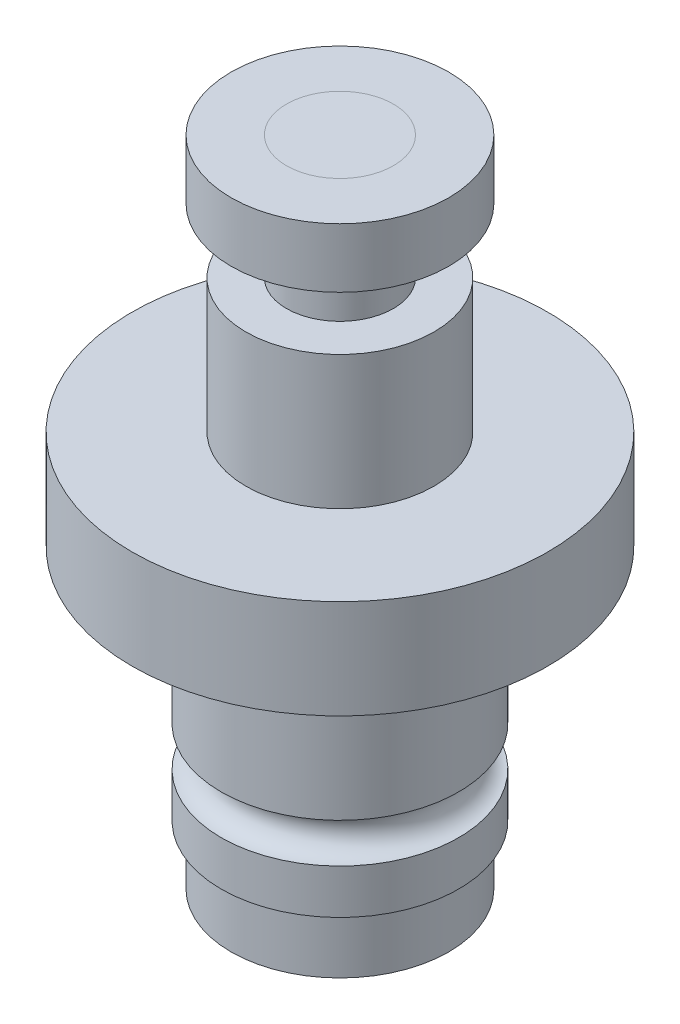
from build123d import *

# Parameters (mm, degrees)
BOSS_EXTRUDE1_DEPTH      = 2.5
BOSS_EXTRUDE1_DEPTH_BACK = 2.5
SKETCH1_R                = 10.5
SKETCH2_R                = 4.75
BOSS_EXTRUDE2_DEPTH      = 6.75
SKETCH3_R                = 2.7
BOSS_EXTRUDE4_DEPTH      = 6.25
SKETCH5_R                = 5.5
SKETCH5_R_2              = 2.7
BOSS_EXTRUDE5_DEPTH      = 3
SKETCH6_R                = 2.5
BOSS_EXTRUDE6_DEPTH      = 15
SKETCH7_R                = 4.875
SKETCH7_R_2              = 2.5
BOSS_EXTRUDE7_DEPTH      = 1
SKETCH8_R                = 6
SKETCH8_R_2              = 2.5
BOSS_EXTRUDE8_DEPTH      = 11
SKETCH9_R                = 1
SKETCH10_R               = 5.5
SKETCH10_R_2             = 2.5
BOSS_EXTRUDE12_DEPTH     = 3


with BuildPart() as part:
    # Sketch1 → Boss-Extrude1 (new, two sides: drawn at the far end of the back side and taken through both)
    with BuildSketch(Plane(origin=(0, 0, 0), x_dir=(1, 0, 0), z_dir=(0, 1, 0)).offset(-BOSS_EXTRUDE1_DEPTH_BACK)):
        Circle(SKETCH1_R)
    extrude(amount=BOSS_EXTRUDE1_DEPTH + BOSS_EXTRUDE1_DEPTH_BACK)

    # Sketch2 → Boss-Extrude2 (add)
    with BuildSketch(Plane(origin=(0, 2.5, 0), x_dir=(1, 0, 0), z_dir=(0, 1, 0))):
        Circle(SKETCH2_R)
    extrude(amount=BOSS_EXTRUDE2_DEPTH)

    # Sketch3 → Boss-Extrude4 (add)
    with BuildSketch(Plane(origin=(0, 9.25, 0), x_dir=(1, 0, 0), z_dir=(0, 1, 0))):
        Circle(SKETCH3_R)
    extrude(amount=BOSS_EXTRUDE4_DEPTH)


with BuildPart() as body_2:
    # Sketch5 → Boss-Extrude5 (new body)
    with BuildSketch(Plane(origin=(0, 15.5, 0), x_dir=(1, 0, 0), z_dir=(0, 1, 0))):
        Circle(SKETCH5_R)
        Circle(SKETCH5_R_2, mode=Mode.SUBTRACT)
    extrude(amount=-BOSS_EXTRUDE5_DEPTH)


with BuildPart() as body_3:
    # Sketch6 → Boss-Extrude6 (new body)
    with BuildSketch(Plane.XZ.offset(2.5)):
        Circle(SKETCH6_R)
    extrude(amount=BOSS_EXTRUDE6_DEPTH)


with BuildPart() as body_4:
    # Sketch7 → Boss-Extrude7 (new body)
    with BuildSketch(Plane.XZ.offset(2.5)):
        Circle(SKETCH7_R)
        Circle(SKETCH7_R_2, mode=Mode.SUBTRACT)
    extrude(amount=BOSS_EXTRUDE7_DEPTH)


with BuildPart() as body_5:
    # Sketch8 → Boss-Extrude8 (new body)
    with BuildSketch(Plane.XZ.offset(3.5)):
        Circle(SKETCH8_R)
        Circle(SKETCH8_R_2, mode=Mode.SUBTRACT)
    extrude(amount=BOSS_EXTRUDE8_DEPTH)

    # Sketch9 → Cut-Revolve1 (revolve, cut)
    with BuildSketch(Plane.XY):
        with Locations((6, -11.25)):
            Circle(SKETCH9_R)
    revolve(axis=Axis((0, -29.718418544, 0), (0, 1, 0)), mode=Mode.SUBTRACT)


with BuildPart() as body_6:
    # Sketch10 → Boss-Extrude12 (new body)
    with BuildSketch(Plane.XZ.offset(14.5)):
        Circle(SKETCH10_R)
        Circle(SKETCH10_R_2, mode=Mode.SUBTRACT)
    extrude(amount=BOSS_EXTRUDE12_DEPTH)


solid = Compound([part.part, body_2.part, body_3.part, body_4.part, body_5.part, body_6.part])
